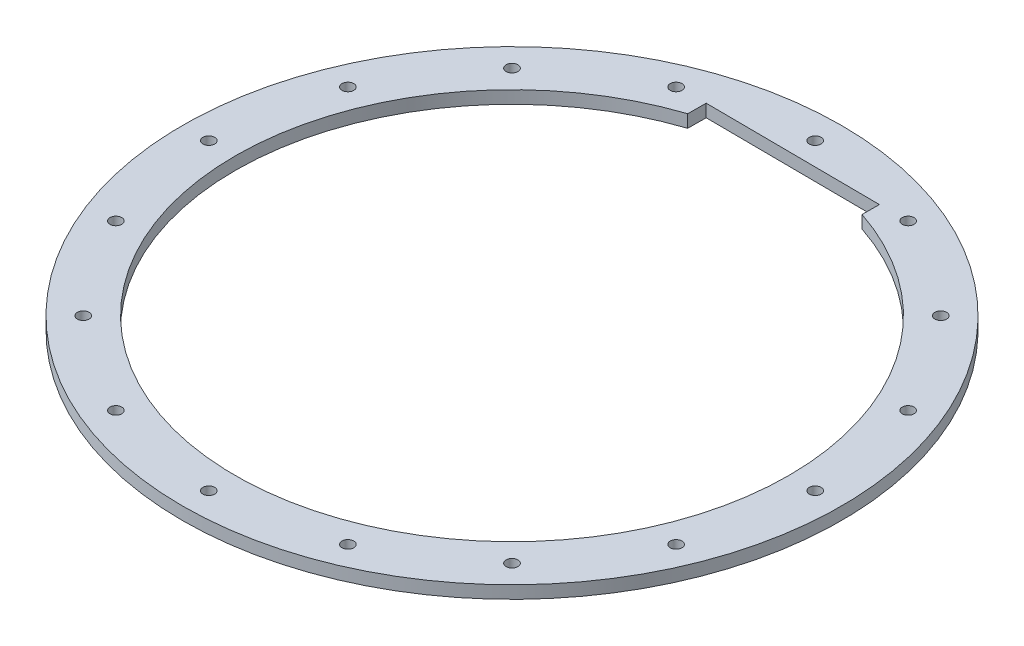
from build123d import *

# Parameters (mm, degrees)
SKETCH2_R           = 79.375
SKETCH2_R_2         = 66.675
SKETCH2_R_3         = 1.4224
BOSS_EXTRUDE1_DEPTH = 3.048
CUT_EXTRUDE2_DEPTH  = 4.048


with BuildPart() as part:
    # Sketch2 → Boss-Extrude1 (new body)
    with BuildSketch(Plane(origin=(0, 0, 0), x_dir=(1, 0, 0), z_dir=(0, 1, 0))):
        Circle(SKETCH2_R)
        Circle(SKETCH2_R_2, mode=Mode.SUBTRACT)
        with Locations((0, 73.025)):
            Circle(SKETCH2_R_3, mode=Mode.SUBTRACT)
        with Locations((27.945457648, 67.466302862)):
            Circle(SKETCH2_R_3, mode=Mode.SUBTRACT)
        with Locations((51.636472696, 51.636472696)):
            Circle(SKETCH2_R_3, mode=Mode.SUBTRACT)
        with Locations((67.466302862, 27.945457648)):
            Circle(SKETCH2_R_3, mode=Mode.SUBTRACT)
        with Locations((73.025, 0)):
            Circle(SKETCH2_R_3, mode=Mode.SUBTRACT)
        with Locations((67.466302862, -27.945457648)):
            Circle(SKETCH2_R_3, mode=Mode.SUBTRACT)
        with Locations((51.636472696, -51.636472696)):
            Circle(SKETCH2_R_3, mode=Mode.SUBTRACT)
        with Locations((27.945457648, -67.466302862)):
            Circle(SKETCH2_R_3, mode=Mode.SUBTRACT)
        with Locations((0, -73.025)):
            Circle(SKETCH2_R_3, mode=Mode.SUBTRACT)
        with Locations((-27.945457648, -67.466302862)):
            Circle(SKETCH2_R_3, mode=Mode.SUBTRACT)
        with Locations((-51.636472696, -51.636472696)):
            Circle(SKETCH2_R_3, mode=Mode.SUBTRACT)
        with Locations((-67.466302862, -27.945457648)):
            Circle(SKETCH2_R_3, mode=Mode.SUBTRACT)
        with Locations((-73.025, 0)):
            Circle(SKETCH2_R_3, mode=Mode.SUBTRACT)
        with Locations((-67.466302862, 27.945457648)):
            Circle(SKETCH2_R_3, mode=Mode.SUBTRACT)
        with Locations((-51.636472696, 51.636472696)):
            Circle(SKETCH2_R_3, mode=Mode.SUBTRACT)
        with Locations((-27.945457648, 67.466302862)):
            Circle(SKETCH2_R_3, mode=Mode.SUBTRACT)
    extrude(amount=BOSS_EXTRUDE1_DEPTH)

    # Sketch5 → Cut-Extrude2 (cut, through all)
    with BuildSketch(Plane(origin=(0, 0, 0), x_dir=(-1, 0, 0), z_dir=(0, -1, 0))):
        with BuildLine():
            Line((20.972211437, 63.290773202), (20.941758021, 67.713419083))
            Line((20.941758021, 67.713419083), (-21.068846043, 67.42414284))
            Line((-21.068846043, 67.42414284), (-21.040229048, 63.268194115))
            ThreePointArc((-21.040229048, 63.268194115), (-0.03583368, 66.674990371), (20.972211437, 63.290773202))
        make_face()
    extrude(amount=-CUT_EXTRUDE2_DEPTH, mode=Mode.SUBTRACT)


solid = part.part
